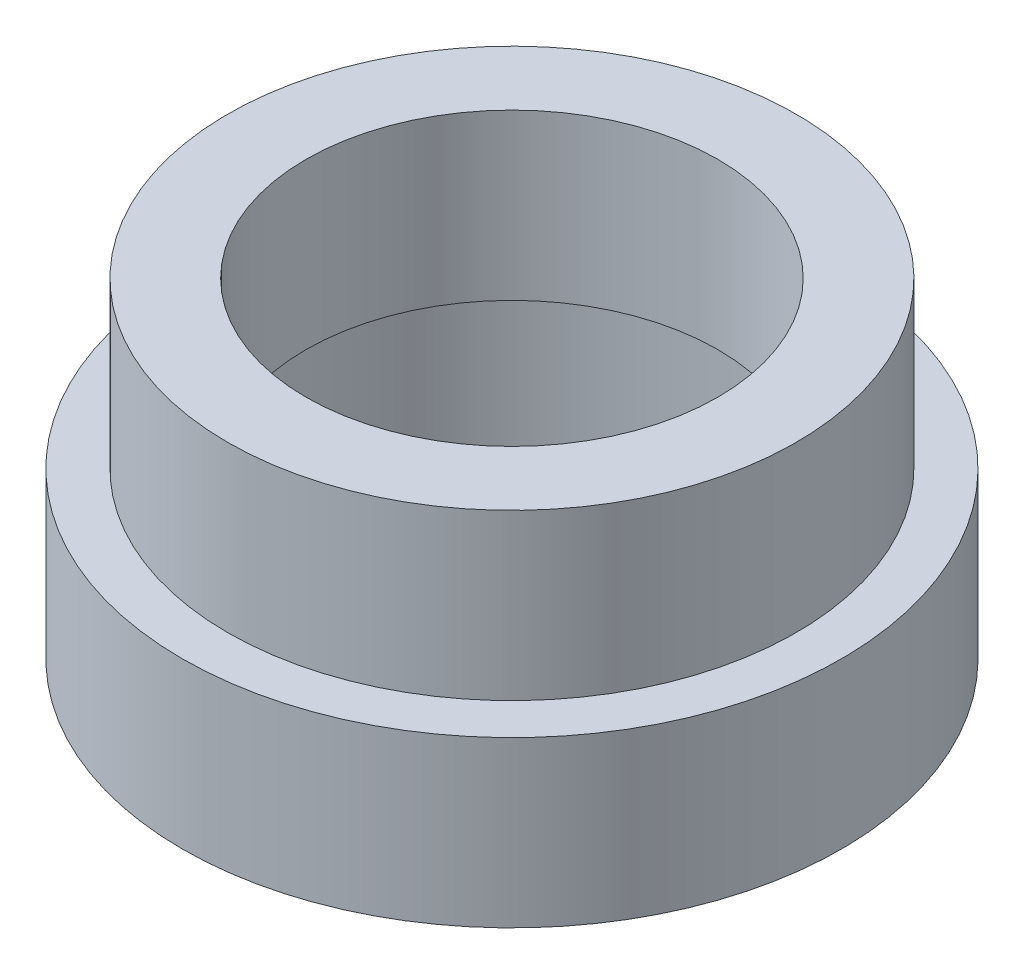
from build123d import *

# Parameters (mm, degrees)
SKETCH2_R           = 17.25
SKETCH2_R_2         = 15
BOSS_EXTRUDE4_DEPTH = 20
SKETCH4_R           = 20
SKETCH4_R_2         = 15
BOSS_EXTRUDE6_DEPTH = 10
BOSS_EXTRUDE7_START = 10
SKETCH5_R           = 15
SKETCH5_R_2         = 12.5
BOSS_EXTRUDE7_DEPTH = 10


with BuildPart() as part:
    # Sketch2 → Boss-Extrude4 (new body)
    with BuildSketch(Plane(origin=(0, 0, 0), x_dir=(1, 0, 0), z_dir=(0, 1, 0))):
        Circle(SKETCH2_R)
        Circle(SKETCH2_R_2, mode=Mode.SUBTRACT)
    extrude(amount=BOSS_EXTRUDE4_DEPTH)

    # Sketch4 → Boss-Extrude6 (add)
    with BuildSketch(Plane(origin=(0, 0, 0), x_dir=(1, 0, 0), z_dir=(0, 1, 0))):
        Circle(SKETCH4_R)
        Circle(SKETCH4_R_2, mode=Mode.SUBTRACT)
    extrude(amount=BOSS_EXTRUDE6_DEPTH)

    # Sketch5 → Boss-Extrude7 (add)
    with BuildSketch(Plane(origin=(0, 0, 0), x_dir=(1, 0, 0), z_dir=(0, 1, 0)).offset(BOSS_EXTRUDE7_START)):
        Circle(SKETCH5_R)
        Circle(SKETCH5_R_2, mode=Mode.SUBTRACT)
    extrude(amount=BOSS_EXTRUDE7_DEPTH)


solid = part.part
